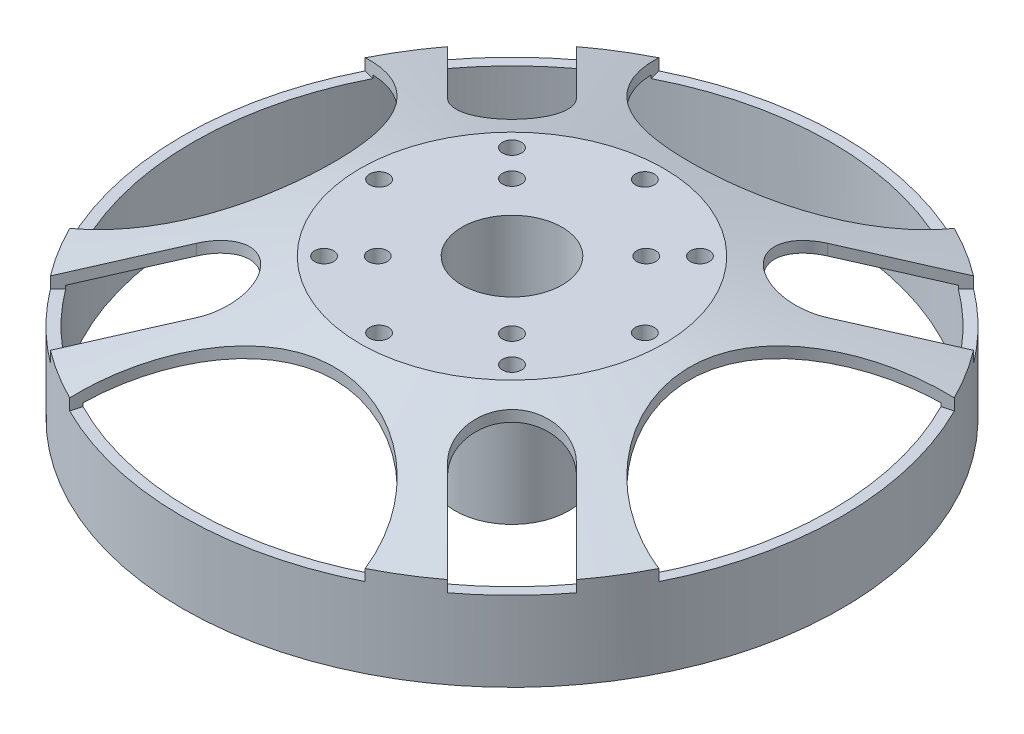
from build123d import *

# Parameters (mm, degrees)
SKETCH1_R             = 43.4
SKETCH1_R_2           = 42
BOSS_EXTRUDE1_DEPTH   = 10.5
SKETCH3_R             = 8.5
BOSS_EXTRUDE2_DEPTH   = 5
SKETCH4_R             = 7.5
BOSS_EXTRUDE3_DEPTH   = 18
SKETCH5_R             = 6.6
CUT_EXTRUDE1_DEPTH    = 20
SKETCH6_R             = 3
CUT_EXTRUDE2_DEPTH    = 67.386820981
SKETCH7_R             = 20
CUT_EXTRUDE3_DEPTH    = 8
M3_TAPPED_HOLE2_D     = 2.5
M3_TAPPED_HOLE3_D     = 2.5
CIRPATTERN1_COUNT     = 8
CIRPATTERN2_COUNT     = 4
CIRPATTERN2_COPY_1_D  = 2.5
CIRPATTERN2_COPY_2_D  = 2.5
CIRPATTERN2_COPY_3_D  = 2.5
CIRPATTERN2_COPY_4_D  = 2.5
CIRPATTERN2_COPY_5_D  = 2.5
CIRPATTERN2_COPY_6_D  = 2.5
CIRPATTERN2_COPY_7_D  = 2.5
CIRPATTERN2_COPY_8_D  = 2.5
CIRPATTERN2_COPY_9_D  = 2.5
CIRPATTERN2_COPY_10_D = 2.5
CIRPATTERN2_COPY_11_D = 2.5
CIRPATTERN2_COPY_12_D = 2.5
CIRPATTERN2_COPY_13_D = 2.5
CIRPATTERN2_COPY_14_D = 2.5
CIRPATTERN2_COPY_15_D = 2.5
CIRPATTERN2_COPY_16_D = 2.5
CIRPATTERN2_COPY_17_D = 2.5
CIRPATTERN2_COPY_18_D = 2.5
CIRPATTERN2_COPY_19_D = 2.5
CIRPATTERN2_COPY_20_D = 2.5
CIRPATTERN2_COPY_21_D = 2.5
CIRPATTERN2_COPY_22_D = 2.5
CIRPATTERN2_COPY_23_D = 2.5
CIRPATTERN2_COPY_24_D = 2.5


with BuildPart() as part:
    # Sketch1 → Boss-Extrude1 (new body)
    with BuildSketch(Plane(origin=(0, 0, 0), x_dir=(1, 0, 0), z_dir=(0, 1, 0))):
        with Locations(Location((0, 0, 0), (0, 0, 90))):
            Circle(SKETCH1_R)
        with Locations(Location((0, 0, 0), (0, 0, 90))):
            Circle(SKETCH1_R_2, mode=Mode.SUBTRACT)
    extrude(amount=BOSS_EXTRUDE1_DEPTH)

    # Sketch2 → Revolve1 (revolve)
    with BuildSketch(Plane.XY, mode=Mode.PRIVATE) as revolve1_sk:
        Polygon((0, 18.5), (-20, 18.5), (-43.4, 12), (-43.4, 10.5), (-42, 10.5), (-42, 10.935880091), (-23.049168326, 16.2), (0, 16.2), align=None)
    revolve(revolve1_sk.sketch.rotate(Axis((0, 18.5, 0), (0, -1, 0)), 90), axis=Axis((0, 18.5, 0), (0, -1, 0)))

    # Sketch3 → Boss-Extrude2 (add)
    with BuildSketch(Plane.XZ.offset(-16.2)):
        Circle(SKETCH3_R)
    extrude(amount=BOSS_EXTRUDE2_DEPTH)

    # Sketch4 → Boss-Extrude3 (add)
    with BuildSketch(Plane.XZ.offset(-11.2)):
        Circle(SKETCH4_R)
    extrude(amount=BOSS_EXTRUDE3_DEPTH)

    # Sketch5 → Cut-Extrude1 (cut)
    with BuildSketch(Plane(origin=(0, 18.5, 0), x_dir=(1, 0, 0), z_dir=(0, 1, 0))):
        with Locations(Location((0, 0, 0), (0, 0, 180))):
            Circle(SKETCH5_R)
    extrude(amount=-CUT_EXTRUDE1_DEPTH, mode=Mode.SUBTRACT)

    # Sketch6 → Cut-Extrude2 (cut, through all)
    with BuildSketch(Plane.XZ.offset(6.8)):
        Circle(SKETCH6_R)
    extrude(amount=-CUT_EXTRUDE2_DEPTH, mode=Mode.SUBTRACT)

    # Sketch7 → Cut-Extrude3 (cut)
    with BuildSketch(Plane(origin=(0, 18.5, 0), x_dir=(1, 0, 0), z_dir=(0, 1, 0))):
        with Locations((0, 43.4)):
            Circle(SKETCH7_R)
        with Locations((43.4, 0)):
            Circle(SKETCH7_R)
        with Locations((0, -43.4)):
            Circle(SKETCH7_R)
        with Locations((-43.4, 0)):
            Circle(SKETCH7_R)
        with BuildLine():
            Line((-26.445793616, 34.931074991), (-16.54629868, 25.031580054))
            ThreePointArc((-16.54629868, 25.031580054), (-16.54629868, 16.54629868), (-25.031580054, 16.54629868))
            Line((-25.031580054, 16.54629868), (-34.931074991, 26.445793616))
            ThreePointArc((-34.931074991, 26.445793616), (-34.931074991, 34.931074991), (-26.445793616, 34.931074991))
        make_face()
        with BuildLine():
            Line((26.445793616, 34.931074991), (16.54629868, 25.031580054))
            ThreePointArc((16.54629868, 25.031580054), (16.54629868, 16.54629868), (25.031580054, 16.54629868))
            Line((25.031580054, 16.54629868), (34.931074991, 26.445793616))
            ThreePointArc((34.931074991, 26.445793616), (34.931074991, 34.931074991), (26.445793616, 34.931074991))
        make_face()
        with BuildLine():
            Line((34.931074991, -26.445793616), (25.031580054, -16.54629868))
            ThreePointArc((25.031580054, -16.54629868), (16.54629868, -16.54629868), (16.54629868, -25.031580054))
            Line((16.54629868, -25.031580054), (26.445793616, -34.931074991))
            ThreePointArc((26.445793616, -34.931074991), (34.931074991, -34.931074991), (34.931074991, -26.445793616))
        make_face()
        with BuildLine():
            Line((-26.445793616, -34.931074991), (-16.54629868, -25.031580054))
            ThreePointArc((-16.54629868, -25.031580054), (-16.54629868, -16.54629868), (-25.031580054, -16.54629868))
            Line((-25.031580054, -16.54629868), (-34.931074991, -26.445793616))
            ThreePointArc((-34.931074991, -26.445793616), (-34.931074991, -34.931074991), (-26.445793616, -34.931074991))
        make_face()
    extrude(amount=-CUT_EXTRUDE3_DEPTH, mode=Mode.SUBTRACT)

    # M3 Tapped Hole2 (through all)
    with Locations(Plane(origin=(12.374368671, 18.5, -12.374368671), x_dir=(1, 0, 0), z_dir=(0, 1, 0))):
        with Locations((0, 0)):
            m3_tapped_hole2 = Hole(M3_TAPPED_HOLE2_D / 2)

    # M3 Tapped Hole3 (through all)
    with Locations(Plane(origin=(8.838834765, 18.5, -8.838834765), x_dir=(1, 0, 0), z_dir=(0, 1, 0))):
        with Locations((0, 0)):
            m3_tapped_hole3 = Hole(M3_TAPPED_HOLE3_D / 2)

    # CirPattern1: M3 Tapped Hole2 ×8 about axis
    cirpattern1_axis = Axis((0, 0, 0), (0, 1, 0))
    for i in range(1, CIRPATTERN1_COUNT):
        add(m3_tapped_hole2.rotate(cirpattern1_axis, i * 360 / CIRPATTERN1_COUNT), mode=Mode.SUBTRACT)

    # CirPattern2: M3 Tapped Hole3 ×4 about axis
    cirpattern2_axis = Axis((0, 0, 0), (0, 1, 0))
    for i in range(1, CIRPATTERN2_COUNT):
        add(m3_tapped_hole3.rotate(cirpattern2_axis, i * 360 / CIRPATTERN2_COUNT), mode=Mode.SUBTRACT)

    # CirPattern2 copy 1 (through all)
    with Locations(Plane(origin=(-17.5, 18.5, 0), x_dir=(-0.7071067811865475, 0, -0.7071067811865476), z_dir=(0, 1, 0))):
        with Locations((0, 0)):
            Hole(CIRPATTERN2_COPY_1_D / 2)

    # CirPattern2 copy 2 (through all)
    with Locations(Plane(origin=(0, 18.5, 17.5), x_dir=(-0.7071067811865477, 0, 0.7071067811865474), z_dir=(0, 1, 0))):
        with Locations((0, 0)):
            Hole(CIRPATTERN2_COPY_2_D / 2)

    # CirPattern2 copy 3 (through all)
    with Locations(Plane(origin=(17.5, 18.5, 0), x_dir=(0.7071067811865474, 0, 0.7071067811865477), z_dir=(0, 1, 0))):
        with Locations((0, 0)):
            Hole(CIRPATTERN2_COPY_3_D / 2)

    # CirPattern2 copy 4 (through all)
    with Locations(Plane(origin=(-12.374368671, 18.5, 12.374368671), x_dir=(-1, 0, 0), z_dir=(0, 1, 0))):
        with Locations((0, 0)):
            Hole(CIRPATTERN2_COPY_4_D / 2)

    # CirPattern2 copy 5 (through all)
    with Locations(Plane(origin=(12.374368671, 18.5, 12.374368671), x_dir=(0, 0, 1), z_dir=(0, 1, 0))):
        with Locations((0, 0)):
            Hole(CIRPATTERN2_COPY_5_D / 2)

    # CirPattern2 copy 6 (through all)
    with Locations(Plane(origin=(12.374368671, 18.5, -12.374368671), x_dir=(1, 0, 0), z_dir=(0, 1, 0))):
        with Locations((0, 0)):
            Hole(CIRPATTERN2_COPY_6_D / 2)

    # CirPattern2 copy 7 (through all)
    with Locations(Plane(origin=(0, 18.5, 17.5), x_dir=(-0.7071067811865476, 0, 0.7071067811865475), z_dir=(0, 1, 0))):
        with Locations((0, 0)):
            Hole(CIRPATTERN2_COPY_7_D / 2)

    # CirPattern2 copy 8 (through all)
    with Locations(Plane(origin=(17.5, 18.5, 0), x_dir=(0.7071067811865474, 0, 0.7071067811865477), z_dir=(0, 1, 0))):
        with Locations((0, 0)):
            Hole(CIRPATTERN2_COPY_8_D / 2)

    # CirPattern2 copy 9 (through all)
    with Locations(Plane(origin=(0, 18.5, -17.5), x_dir=(0.7071067811865477, 0, -0.7071067811865474), z_dir=(0, 1, 0))):
        with Locations((0, 0)):
            Hole(CIRPATTERN2_COPY_9_D / 2)

    # CirPattern2 copy 10 (through all)
    with Locations(Plane(origin=(12.374368671, 18.5, 12.374368671), x_dir=(0, 0, 1), z_dir=(0, 1, 0))):
        with Locations((0, 0)):
            Hole(CIRPATTERN2_COPY_10_D / 2)

    # CirPattern2 copy 11 (through all)
    with Locations(Plane(origin=(12.374368671, 18.5, -12.374368671), x_dir=(1, 0, 0), z_dir=(0, 1, 0))):
        with Locations((0, 0)):
            Hole(CIRPATTERN2_COPY_11_D / 2)

    # CirPattern2 copy 12 (through all)
    with Locations(Plane(origin=(-12.374368671, 18.5, -12.374368671), x_dir=(0, 0, -1), z_dir=(0, 1, 0))):
        with Locations((0, 0)):
            Hole(CIRPATTERN2_COPY_12_D / 2)

    # CirPattern2 copy 13 (through all)
    with Locations(Plane(origin=(17.5, 18.5, 0), x_dir=(0.7071067811865475, 0, 0.7071067811865477), z_dir=(0, 1, 0))):
        with Locations((0, 0)):
            Hole(CIRPATTERN2_COPY_13_D / 2)

    # CirPattern2 copy 14 (through all)
    with Locations(Plane(origin=(0, 18.5, -17.5), x_dir=(0.7071067811865478, 0, -0.7071067811865474), z_dir=(0, 1, 0))):
        with Locations((0, 0)):
            Hole(CIRPATTERN2_COPY_14_D / 2)

    # CirPattern2 copy 15 (through all)
    with Locations(Plane(origin=(-17.5, 18.5, 0), x_dir=(-0.7071067811865474, 0, -0.7071067811865478), z_dir=(0, 1, 0))):
        with Locations((0, 0)):
            Hole(CIRPATTERN2_COPY_15_D / 2)

    # CirPattern2 copy 16 (through all)
    with Locations(Plane(origin=(12.374368671, 18.5, -12.374368671), x_dir=(1, 0, 0), z_dir=(0, 1, 0))):
        with Locations((0, 0)):
            Hole(CIRPATTERN2_COPY_16_D / 2)

    # CirPattern2 copy 17 (through all)
    with Locations(Plane(origin=(-12.374368671, 18.5, -12.374368671), x_dir=(0, 0, -1), z_dir=(0, 1, 0))):
        with Locations((0, 0)):
            Hole(CIRPATTERN2_COPY_17_D / 2)

    # CirPattern2 copy 18 (through all)
    with Locations(Plane(origin=(-12.374368671, 18.5, 12.374368671), x_dir=(-1, 0, 0), z_dir=(0, 1, 0))):
        with Locations((0, 0)):
            Hole(CIRPATTERN2_COPY_18_D / 2)

    # CirPattern2 copy 19 (through all)
    with Locations(Plane(origin=(0, 18.5, -17.5), x_dir=(0.7071067811865477, 0, -0.7071067811865474), z_dir=(0, 1, 0))):
        with Locations((0, 0)):
            Hole(CIRPATTERN2_COPY_19_D / 2)

    # CirPattern2 copy 20 (through all)
    with Locations(Plane(origin=(-17.5, 18.5, 0), x_dir=(-0.7071067811865472, 0, -0.7071067811865478), z_dir=(0, 1, 0))):
        with Locations((0, 0)):
            Hole(CIRPATTERN2_COPY_20_D / 2)

    # CirPattern2 copy 21 (through all)
    with Locations(Plane(origin=(0, 18.5, 17.5), x_dir=(-0.7071067811865478, 0, 0.7071067811865472), z_dir=(0, 1, 0))):
        with Locations((0, 0)):
            Hole(CIRPATTERN2_COPY_21_D / 2)

    # CirPattern2 copy 22 (through all)
    with Locations(Plane(origin=(-12.374368671, 18.5, -12.374368671), x_dir=(0, 0, -1), z_dir=(0, 1, 0))):
        with Locations((0, 0)):
            Hole(CIRPATTERN2_COPY_22_D / 2)

    # CirPattern2 copy 23 (through all)
    with Locations(Plane(origin=(-12.374368671, 18.5, 12.374368671), x_dir=(-1, 0, 0), z_dir=(0, 1, 0))):
        with Locations((0, 0)):
            Hole(CIRPATTERN2_COPY_23_D / 2)

    # CirPattern2 copy 24 (through all)
    with Locations(Plane(origin=(12.374368671, 18.5, 12.374368671), x_dir=(0, 0, 1), z_dir=(0, 1, 0))):
        with Locations((0, 0)):
            Hole(CIRPATTERN2_COPY_24_D / 2)


solid = part.part
